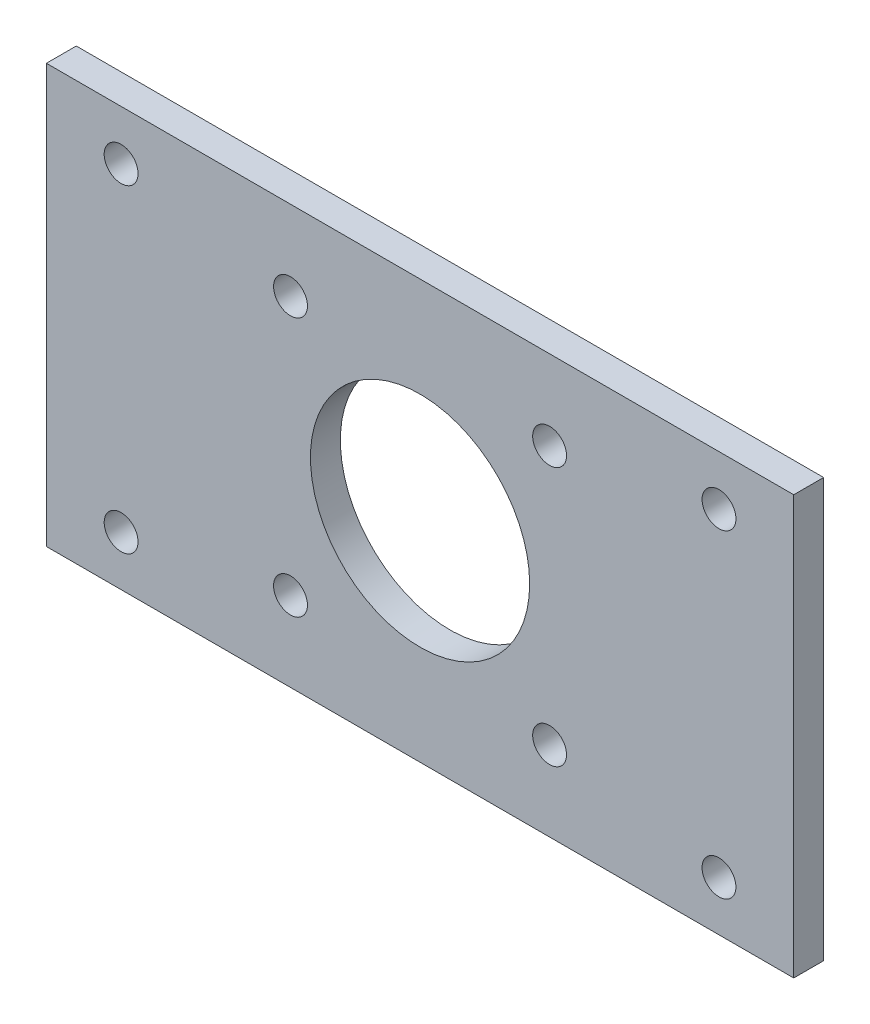
from build123d import *

# Parameters (mm, degrees)
SKETCH1_W            = 75
SKETCH1_H            = 42
BOSS_EXTRUDE1_DEPTH  = 3
SKETCH2_R            = 11
CUT_EXTRUDE1_DEPTH   = 4
M3_CLEARANCE_HOLE1_D = 3.4
M3_CLEARANCE_HOLE2_D = 3.4


with BuildPart() as part:
    # Sketch1 → Boss-Extrude1 (new body)
    with BuildSketch(Plane.XY):
        Rectangle(SKETCH1_W, SKETCH1_H)
    extrude(amount=BOSS_EXTRUDE1_DEPTH)

    # Sketch2 → Cut-Extrude1 (cut, through all)
    with BuildSketch(Plane.XY.offset(3)):
        Circle(SKETCH2_R)
    extrude(amount=-CUT_EXTRUDE1_DEPTH, mode=Mode.SUBTRACT)

    # M3 Clearance Hole1 (through all)
    with Locations(Plane.XY.offset(3)):
        with Locations((-13, -13), (13, -13), (13, 13), (-13, 13)):
            Hole(M3_CLEARANCE_HOLE1_D / 2)

    # M3 Clearance Hole2 (through all)
    with Locations(Plane.XY.offset(3)):
        with Locations((-30, -16), (-30, 16), (30, -16), (30, 16)):
            Hole(M3_CLEARANCE_HOLE2_D / 2)


solid = part.part
